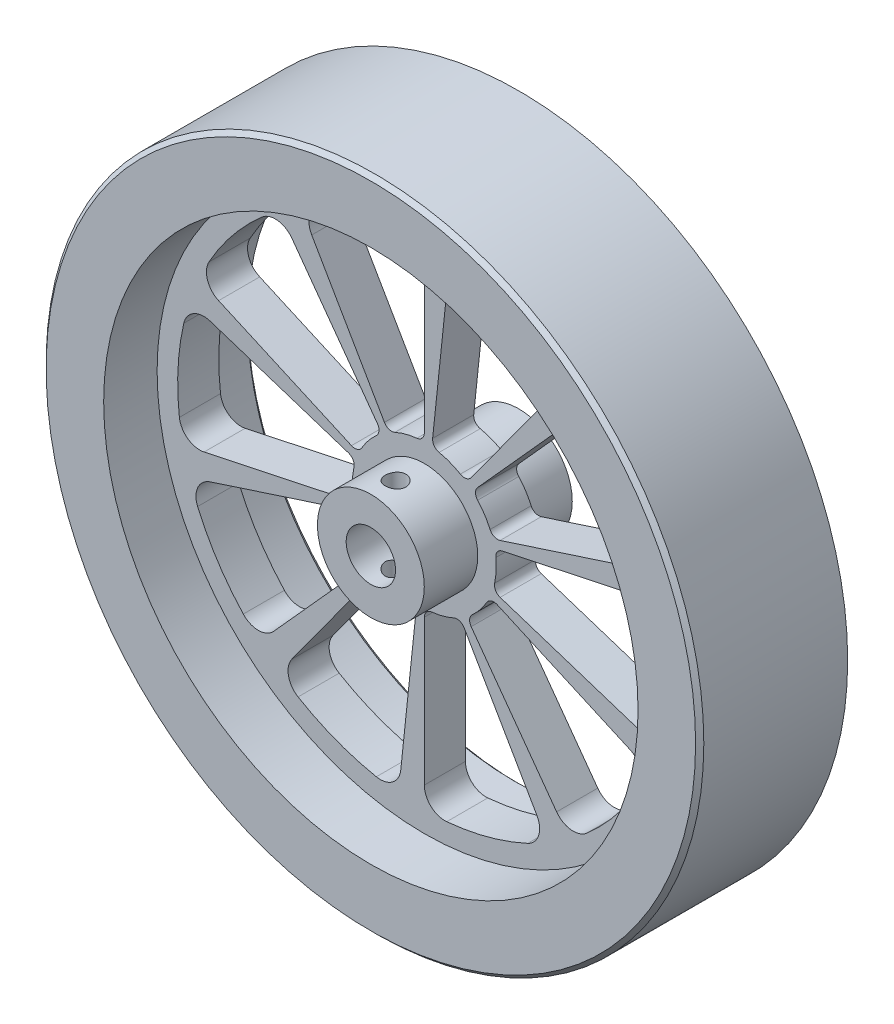
from build123d import *

# Parameters (mm, degrees)
SKETCH1_R           = 80
SKETCH1_R_2         = 6
BOSS_EXTRUDE1_DEPTH = 18
SKETCH2_R           = 65
SKETCH2_R_2         = 13
CUT_EXTRUDE1_DEPTH  = 13
CUT_EXTRUDE3_DEPTH  = 24
CHAMFER1_SIZE       = 1
SKETCH4_R           = 2.5
CUT_EXTRUDE4_DEPTH  = 13


with BuildPart() as part:
    # Sketch1 → Boss-Extrude1 (new body, symmetric)
    with BuildSketch(Plane.XY):
        Circle(SKETCH1_R)
        Circle(SKETCH1_R_2, mode=Mode.SUBTRACT)
    extrude(amount=BOSS_EXTRUDE1_DEPTH, both=True)

    # Sketch2 → Cut-Extrude1 (cut)
    with BuildSketch(Plane.XY.offset(18)):
        Circle(SKETCH2_R)
        Circle(SKETCH2_R_2, mode=Mode.SUBTRACT)
    cut_extrude1 = extrude(amount=-CUT_EXTRUDE1_DEPTH, mode=Mode.SUBTRACT)

    # Mirror1: Cut-Extrude1 across plane
    add(cut_extrude1.mirror(Plane.XY), mode=Mode.SUBTRACT)

    # Sketch3 → Cut-Extrude3 (cut, through all)
    with BuildSketch(Plane.XY.offset(5)):
        with BuildLine():
            Line((0, 19.397164741), (0, 54.772255751))
            ThreePointArc((0, 54.772255751), (-1.629000688, 58.46500048), (-5.454545455, 59.751551728))
            ThreePointArc((-5.454545455, 59.751551728), (-15.529142706, 57.955549577), (-25.152000934, 54.473634439))
            ThreePointArc((-25.152000934, 54.473634439), (-27.821744262, 51.446675992), (-27.386127875, 47.434164903))
            Line((-27.386127875, 47.434164903), (-9.698582371, 16.798437427))
            ThreePointArc((-9.698582371, 16.798437427), (-8.582686936, 15.895715021), (-7.149451403, 15.972956666))
            ThreePointArc((-7.149451403, 15.972956666), (-4.529333289, 16.90370196), (-1.794871795, 17.407711947))
            ThreePointArc((-1.794871795, 17.407711947), (-0.515032591, 18.057436487), (0, 19.397164741))
        make_face()
        with BuildLine():
            Line((2.027555822, 19.290905043), (5.725259723, 54.472207603))
            ThreePointArc((5.725259723, 54.472207603), (7.731333507, 57.974446151), (11.670402764, 58.854071221))
            ThreePointArc((11.670402764, 58.854071221), (21.502076973, 56.01482559), (30.708260938, 51.546122164))
            ThreePointArc((30.708260938, 51.546122164), (33.046975817, 48.256681545), (32.194324165, 44.311685722))
            Line((32.194324165, 44.311685722), (11.401367371, 15.692635918))
            ThreePointArc((11.401367371, 15.692635918), (10.197224742, 14.911501555), (8.779914574, 15.138133969))
            ThreePointArc((8.779914574, 15.138133969), (6.271439117, 16.337657464), (3.604640678, 17.124735489))
            ThreePointArc((3.604640678, 17.124735489), (2.399727275, 17.904680395), (2.027555822, 19.290905043))
        make_face()
        with BuildLine():
            Line((12.979236605, 14.414902606), (36.649792702, 40.703718441))
            ThreePointArc((36.649792702, 40.703718441), (40.331304654, 42.35794836), (44.035109268, 40.754253173))
            ThreePointArc((44.035109268, 40.754253173), (50.320234077, 32.678342101), (55.141555387, 23.651825922))
            ThreePointArc((55.141555387, 23.651825922), (55.100130785, 19.615950443), (52.091510744, 16.925557847))
            Line((52.091510744, 16.925557847), (18.447799925, 5.994053548))
            ThreePointArc((18.447799925, 5.994053548), (17.014488815, 6.069879851), (16.001071994, 7.086303341))
            ThreePointArc((16.001071994, 7.086303341), (14.676734939, 9.531183113), (12.981882537, 11.735447405))
            ThreePointArc((12.981882537, 11.735447405), (12.465527231, 13.074666417), (12.979236605, 14.414902606))
        make_face()
        with BuildLine():
            Line((18.973290153, 4.032897318), (53.575350549, 11.387792303))
            ThreePointArc((53.575350549, 11.387792303), (57.526088234, 10.562153989), (59.579900731, 7.087695599))
            ThreePointArc((59.579900731, 7.087695599), (59.917772085, -3.140157375), (58.512649872, -13.276663926))
            ThreePointArc((58.512649872, -13.276663926), (56.106908578, -16.517407005), (52.091510744, -16.925557847))
            Line((52.091510744, -16.925557847), (18.447799925, -5.994053548))
            ThreePointArc((18.447799925, -5.994053548), (17.332796462, -5.090229647), (17.110363769, -3.672254308))
            ThreePointArc((17.110363769, -3.672254308), (17.476016858, -0.915879234), (17.400486505, 1.863617284))
            ThreePointArc((17.400486505, 1.863617284), (17.769919472, 3.250574258), (18.973290153, 4.032897318))
        make_face()
        with BuildLine():
            Line((17.720191741, -7.889537672), (50.036945446, -22.277883438))
            ThreePointArc((50.036945446, -22.277883438), (52.747861348, -25.268024211), (52.36719516, -29.286120792))
            ThreePointArc((52.36719516, -29.286120792), (46.628757687, -37.759223463), (39.533900877, -45.133919412))
            ThreePointArc((39.533900877, -45.133919412), (35.682754298, -46.341676384), (32.194324165, -44.311685722))
            Line((32.194324165, -44.311685722), (11.401367371, -15.692635918))
            ThreePointArc((11.401367371, -15.692635918), (11.03056498, -14.306044431), (11.684078144, -13.028135628))
            ThreePointArc((11.684078144, -13.028135628), (13.600054325, -11.013106843), (15.172696049, -8.720051296))
            ThreePointArc((15.172696049, -8.720051296), (16.286806452, -7.815126784), (17.720191741, -7.889537672))
        make_face()
        with BuildLine():
            Line((9.698582371, -16.798437427), (27.386127875, -47.434164903))
            ThreePointArc((27.386127875, -47.434164903), (27.821744262, -51.446675992), (25.152000934, -54.473634439))
            ThreePointArc((25.152000934, -54.473634439), (15.529142706, -57.955549577), (5.454545455, -59.751551728))
            ThreePointArc((5.454545455, -59.751551728), (1.629000688, -58.46500048), (0, -54.772255751))
            Line((0, -54.772255751), (0, -19.397164741))
            ThreePointArc((0, -19.397164741), (0.515032591, -18.057436487), (1.794871795, -17.407711947))
            ThreePointArc((1.794871795, -17.407711947), (4.529333289, -16.90370196), (7.149451403, -15.972956666))
            ThreePointArc((7.149451403, -15.972956666), (8.582686936, -15.895715021), (9.698582371, -16.798437427))
        make_face()
        with BuildLine():
            Line((-2.027555822, -19.290905043), (-5.725259723, -54.472207603))
            ThreePointArc((-5.725259723, -54.472207603), (-7.731333507, -57.974446151), (-11.670402764, -58.854071221))
            ThreePointArc((-11.670402764, -58.854071221), (-21.502076973, -56.01482559), (-30.708260938, -51.546122164))
            ThreePointArc((-30.708260938, -51.546122164), (-33.046975817, -48.256681545), (-32.194324165, -44.311685722))
            Line((-32.194324165, -44.311685722), (-11.401367371, -15.692635918))
            ThreePointArc((-11.401367371, -15.692635918), (-10.197224742, -14.911501555), (-8.779914574, -15.138133969))
            ThreePointArc((-8.779914574, -15.138133969), (-6.271439117, -16.337657464), (-3.604640678, -17.124735489))
            ThreePointArc((-3.604640678, -17.124735489), (-2.399727275, -17.904680395), (-2.027555822, -19.290905043))
        make_face()
        with BuildLine():
            Line((-12.979236605, -14.414902606), (-36.649792702, -40.703718441))
            ThreePointArc((-36.649792702, -40.703718441), (-40.331304654, -42.35794836), (-44.035109268, -40.754253173))
            ThreePointArc((-44.035109268, -40.754253173), (-50.320234077, -32.678342101), (-55.141555387, -23.651825922))
            ThreePointArc((-55.141555387, -23.651825922), (-55.100130785, -19.615950443), (-52.091510744, -16.925557847))
            Line((-52.091510744, -16.925557847), (-18.447799925, -5.994053548))
            ThreePointArc((-18.447799925, -5.994053548), (-17.014488815, -6.069879851), (-16.001071994, -7.086303341))
            ThreePointArc((-16.001071994, -7.086303341), (-14.676734939, -9.531183113), (-12.981882537, -11.735447405))
            ThreePointArc((-12.981882537, -11.735447405), (-12.465527231, -13.074666417), (-12.979236605, -14.414902606))
        make_face()
        with BuildLine():
            Line((-18.973290153, -4.032897318), (-53.575350549, -11.387792303))
            ThreePointArc((-53.575350549, -11.387792303), (-57.526088234, -10.562153989), (-59.579900731, -7.087695599))
            ThreePointArc((-59.579900731, -7.087695599), (-59.917772085, 3.140157375), (-58.512649872, 13.276663926))
            ThreePointArc((-58.512649872, 13.276663926), (-56.106908578, 16.517407005), (-52.091510744, 16.925557847))
            Line((-52.091510744, 16.925557847), (-18.447799925, 5.994053548))
            ThreePointArc((-18.447799925, 5.994053548), (-17.332796462, 5.090229647), (-17.110363769, 3.672254308))
            ThreePointArc((-17.110363769, 3.672254308), (-17.476016858, 0.915879234), (-17.400486505, -1.863617284))
            ThreePointArc((-17.400486505, -1.863617284), (-17.769919472, -3.250574258), (-18.973290153, -4.032897318))
        make_face()
        with BuildLine():
            Line((-17.720191741, 7.889537672), (-50.036945446, 22.277883438))
            ThreePointArc((-50.036945446, 22.277883438), (-52.747861348, 25.268024211), (-52.36719516, 29.286120792))
            ThreePointArc((-52.36719516, 29.286120792), (-46.628757687, 37.759223463), (-39.533900877, 45.133919412))
            ThreePointArc((-39.533900877, 45.133919412), (-35.682754298, 46.341676384), (-32.194324165, 44.311685722))
            Line((-32.194324165, 44.311685722), (-11.401367371, 15.692635918))
            ThreePointArc((-11.401367371, 15.692635918), (-11.03056498, 14.306044431), (-11.684078144, 13.028135628))
            ThreePointArc((-11.684078144, 13.028135628), (-13.600054325, 11.013106843), (-15.172696049, 8.720051296))
            ThreePointArc((-15.172696049, 8.720051296), (-16.286806452, 7.815126784), (-17.720191741, 7.889537672))
        make_face()
    extrude(amount=-CUT_EXTRUDE3_DEPTH, mode=Mode.SUBTRACT)

    # Chamfer1
    chamfer1_edges = [part.edges().sort_by_distance(p)[0] for p in [
        (-65, 0, -18),
        (-80, 0, 18),
    ]]
    chamfer(chamfer1_edges, length=CHAMFER1_SIZE)

    # Sketch4 → Cut-Extrude4 (cut, symmetric)
    with BuildSketch(Plane(origin=(0, 0, 0), x_dir=(1, 0, 0), z_dir=(0, 1, 0))):
        with Locations((0, -12)):
            Circle(SKETCH4_R)
    extrude(amount=CUT_EXTRUDE4_DEPTH, both=True, mode=Mode.SUBTRACT)


solid = part.part
